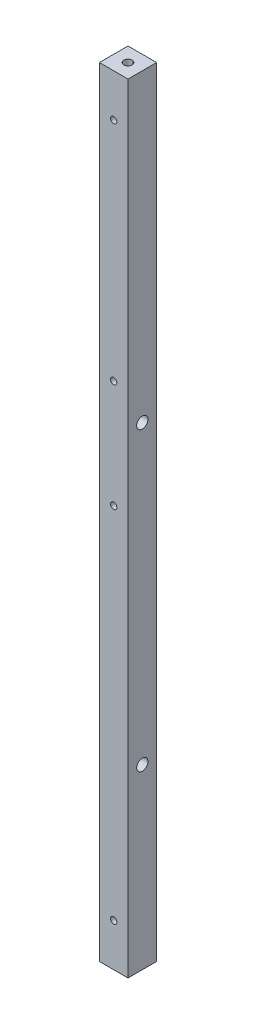
from build123d import *

# Parameters (mm, degrees)
ESQUISSE1_W           = 11.4
ESQUISSE1_H           = 11.4
BOSS_EXTRU_1_DEPTH    = 310
TROU_TARAUD_M31_D     = 2.5
TROU_TARAUD_M41_D     = 3.3
TROU_TARAUD_M41_DEPTH = 11.5
TROU_TARAUD_M41_TIP   = 0.991420021
TROU_TARAUD_M42_D     = 3.3
TROU_TARAUD_M42_DEPTH = 11.5
TROU_TARAUD_M42_TIP   = 0.991420021
D_GAGEMENT_M41_D      = 4.5
D_GAGEMENT_M42_D      = 4.5


with BuildPart() as part:
    # Esquisse1 → Boss.-Extru.1 (new body)
    with BuildSketch(Plane(origin=(0, 0, 0), x_dir=(1, 0, 0), z_dir=(0, 1, 0))):
        Rectangle(ESQUISSE1_W, ESQUISSE1_H)
    extrude(amount=BOSS_EXTRU_1_DEPTH)

    # Trou taraudé M31 (through all)
    with Locations(Plane.XY.offset(5.7)):
        with Locations((0, 293), (0, 17), (0, 160), (0, 203)):
            Hole(TROU_TARAUD_M31_D / 2)

    # Trou taraudé M41
    with Locations(Plane(origin=(0, 310, 0), x_dir=(-1, 0, 0), z_dir=(0, 1, 0))):
        with Locations((0, 0)):
            Hole(TROU_TARAUD_M41_D / 2, depth=TROU_TARAUD_M41_DEPTH)
            with Locations((0, 0, -(TROU_TARAUD_M41_DEPTH + TROU_TARAUD_M41_TIP / 2))):  # 118° drill point
                Cone(0, TROU_TARAUD_M41_D / 2, TROU_TARAUD_M41_TIP, mode=Mode.SUBTRACT)

    # Trou taraudé M42
    with Locations(Plane.XZ):
        with Locations((0, 0)):
            Hole(TROU_TARAUD_M42_D / 2, depth=TROU_TARAUD_M42_DEPTH)
            with Locations((0, 0, -(TROU_TARAUD_M42_DEPTH + TROU_TARAUD_M42_TIP / 2))):  # 118° drill point
                Cone(0, TROU_TARAUD_M42_D / 2, TROU_TARAUD_M42_TIP, mode=Mode.SUBTRACT)

    # Dégagement M41 (through all)
    with Locations(Plane.ZY.offset(5.7)):
        with Locations((0, 70.7)):
            Hole(D_GAGEMENT_M41_D / 2)

    # Dégagement M42 (through all)
    with Locations(Plane.ZY.offset(5.7)):
        with Locations((0, 188.7)):
            Hole(D_GAGEMENT_M42_D / 2)


solid = part.part
